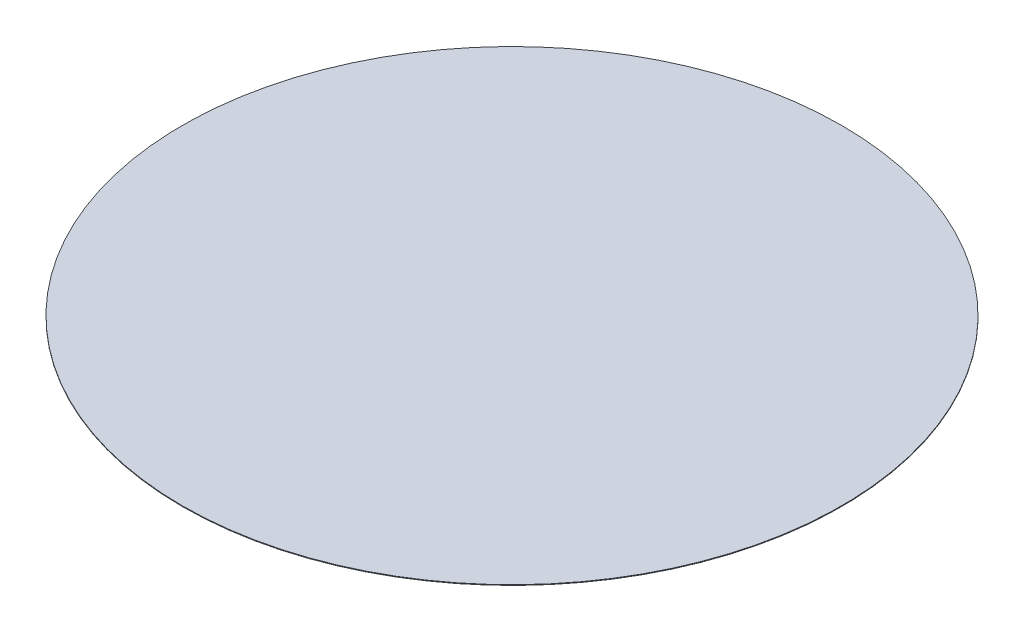
from build123d import *

# Parameters (mm, degrees)
SKETCH1_R           = 2440
BOSS_EXTRUDE1_DEPTH = 5


with BuildPart() as part:
    # Sketch1 → Boss-Extrude1 (new body)
    with BuildSketch(Plane(origin=(0, 0, 0), x_dir=(1, 0, 0), z_dir=(0, 1, 0))):
        Circle(SKETCH1_R)
    extrude(amount=BOSS_EXTRUDE1_DEPTH)


solid = part.part
